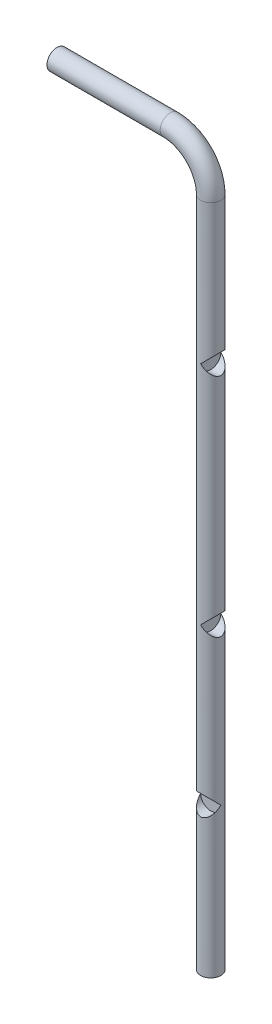
from build123d import *

# Parameters (mm, degrees)
SWEEP1_PROFILE_R   = 12.5
SKETCH8_R          = 12.5
CUT_EXTRUDE3_DEPTH = 21
SKETCH2_R          = 12.5
CUT_EXTRUDE6_DEPTH = 13


with BuildPart() as part:
    # Sweep1: sweep along a path in Sketch1
    with BuildLine(Plane.XY) as sweep1_path:
        Line((0, 0), (0, 830))
        ThreePointArc((0, 830), (-14.644660941, 865.355339059), (-50, 880))
        Line((-50, 880), (-190, 880))
    # Sweep1 profile (on start of the path) → Sweep1 (sweep)
    with BuildSketch(Plane.ZX):
        Circle(SWEEP1_PROFILE_R)
    sweep(path=sweep1_path.line)

    # Sketch8 → Cut-Extrude3 (cut)
    with BuildSketch(Plane(origin=(0, 0, 0), x_dir=(0, 0, -1), z_dir=(1, 0, 0))):
        with Locations((0, 655.01)):
            Circle(SKETCH8_R)
        with Locations((0, 375.5)):
            Circle(SKETCH8_R)
    extrude(amount=CUT_EXTRUDE3_DEPTH, mode=Mode.SUBTRACT)

    # Sketch2 → Cut-Extrude6 (cut)
    with BuildSketch(Plane.XY):
        with Locations((0, 182.5)):
            Circle(SKETCH2_R)
    extrude(amount=CUT_EXTRUDE6_DEPTH, mode=Mode.SUBTRACT)


solid = part.part
